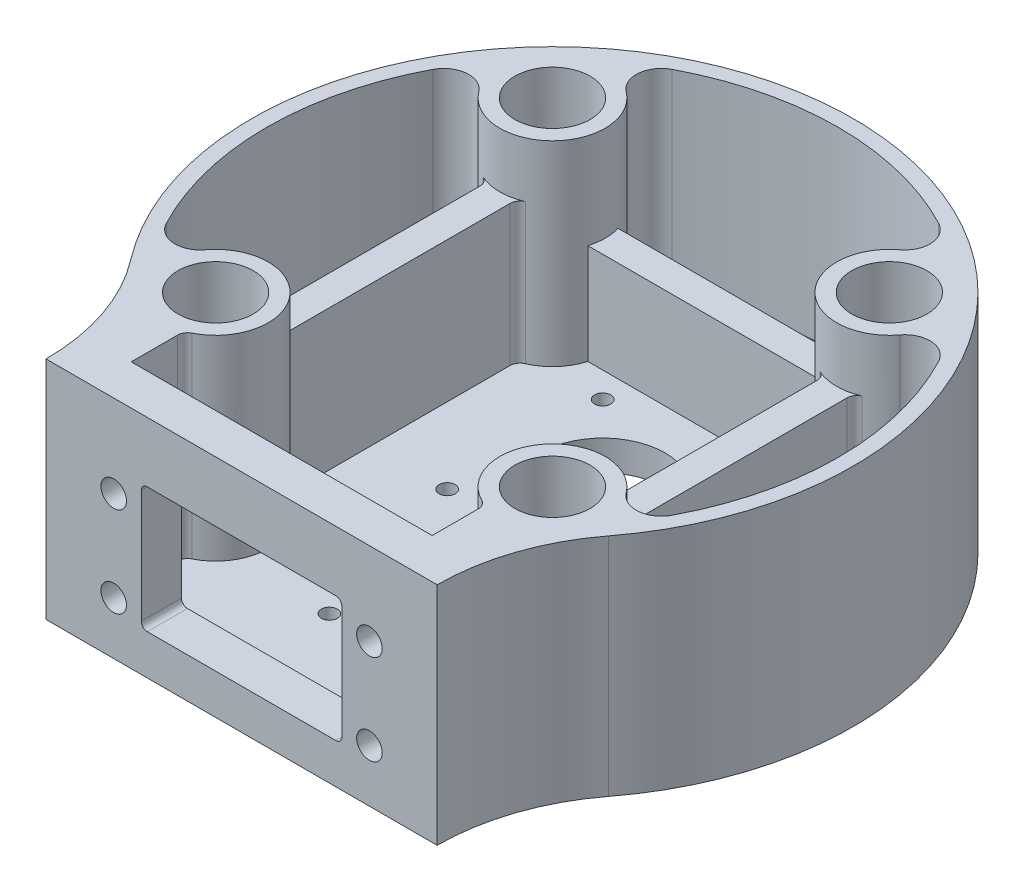
from build123d import *

# Parameters (mm, degrees)
SKETCH1_R           = 7.5
BOSS_EXTRUDE1_DEPTH = 45
BOSS_EXTRUDE2_DEPTH = 6
SKETCH3_R           = 5.25
SKETCH3_R_2         = 4.25
SKETCH3_R_3         = 1.6
CUT_EXTRUDE1_DEPTH  = 7
FILLET1_R           = 5
SKETCH4_R           = 5.1
CUT_EXTRUDE2_DEPTH  = 2
SKETCH5_R           = 12.5
SKETCH5_R_2         = 1.6
CUT_EXTRUDE3_DEPTH  = 46.0000001
CUT_EXTRUDE4_REACH  = 124
SKETCH6_W           = 40
SKETCH6_H           = 25
CUT_EXTRUDE5_REACH  = 124
SKETCH7_R           = 2.55
BOSS_EXTRUDE3_DEPTH = 28
FILLET2_R           = 2
BOSS_EXTRUDE4_DEPTH = 20
FILLET3_R           = 1.2


with BuildPart() as part:
    # Sketch1 → Boss-Extrude1 (new body)
    with BuildSketch(Plane(origin=(0, 0, 0), x_dir=(1, 0, 0), z_dir=(0, 1, 0))):
        with BuildLine():
            ThreePointArc((-47.647058368, -36.465844689), (-41.21916632, -48.520286728), (-39, -62))
            Line((-39, -62), (39, -62))
            ThreePointArc((39, -62), (41.21916632, -48.520286728), (47.647058368, -36.465844689))
            ThreePointArc((47.647058368, -36.465844689), (0, 60), (-47.647058368, -36.465844689))
        make_face()
        with Locations((-33.587572106, -33.587572106)):
            Circle(SKETCH1_R, mode=Mode.SUBTRACT)
        with Locations((33.587572106, -33.587572106)):
            Circle(SKETCH1_R, mode=Mode.SUBTRACT)
        with Locations((-33.587572106, 33.587572106)):
            Circle(SKETCH1_R, mode=Mode.SUBTRACT)
        with BuildLine():
            Line((30, -54), (-30, -54))
            Line((-30, -54), (-30, -48.466483264))
            ThreePointArc((-30, -48.466483264), (-33.435692219, -46.163345696), (-36.695320422, -43.617123463))
            ThreePointArc((-36.695320422, -43.617123463), (-33.334442408, -44.084520489), (-30, -43.455668497))
            ThreePointArc((-30, -43.455668497), (-28.91848754, -24.182804735), (-43.617123463, -36.695320422))
            ThreePointArc((-43.617123463, -36.695320422), (-57, 0), (-43.617123463, 36.695320422))
            ThreePointArc((-43.617123463, 36.695320422), (-26.162950904, 26.162950904), (-36.695320422, 43.617123463))
            ThreePointArc((-36.695320422, 43.617123463), (0, 57), (36.695320422, 43.617123463))
            ThreePointArc((36.695320422, 43.617123463), (26.162950904, 26.162950904), (43.617123463, 36.695320422))
            ThreePointArc((43.617123463, 36.695320422), (57, 0), (43.617123463, -36.695320422))
            ThreePointArc((43.617123463, -36.695320422), (28.91848754, -24.182804735), (30, -43.455668497))
            ThreePointArc((30, -43.455668497), (33.334442408, -44.084520489), (36.695320422, -43.617123463))
            ThreePointArc((36.695320422, -43.617123463), (33.435692219, -46.163345696), (30, -48.466483264))
            Line((30, -48.466483264), (30, -54))
        make_face(mode=Mode.SUBTRACT)
        with Locations((33.587572106, 33.587572106)):
            Circle(SKETCH1_R, mode=Mode.SUBTRACT)
        with BuildLine():
            Line((30, -43.455668497), (30, -48.466483264))
            ThreePointArc((30, -48.466483264), (33.435692219, -46.163345696), (36.695320422, -43.617123463))
            ThreePointArc((36.695320422, -43.617123463), (33.334442408, -44.084520489), (30, -43.455668497))
        make_face()
        with BuildLine():
            ThreePointArc((-36.695320422, -43.617123463), (-33.435692219, -46.163345696), (-30, -48.466483264))
            Line((-30, -48.466483264), (-30, -43.455668497))
            ThreePointArc((-30, -43.455668497), (-33.334442408, -44.084520489), (-36.695320422, -43.617123463))
        make_face()
    extrude(amount=BOSS_EXTRUDE1_DEPTH)

    # Sketch2 → Boss-Extrude2 (add)
    with BuildSketch(Plane.XZ):
        with BuildLine():
            Line((39, 62), (-39, 62))
            ThreePointArc((-39, 62), (-41.21916632, 48.520286728), (-47.647058368, 36.465844689))
            ThreePointArc((-47.647058368, 36.465844689), (0, -60), (47.647058368, 36.465844689))
            ThreePointArc((47.647058368, 36.465844689), (41.21916632, 48.520286728), (39, 62))
        make_face()
    extrude(amount=-BOSS_EXTRUDE2_DEPTH)

    # Sketch3 → Cut-Extrude1 (cut, through all)
    with BuildSketch(Plane(origin=(0, 6, 0), x_dir=(1, 0, 0), z_dir=(0, 1, 0))):
        with Locations((-33.587572106, 33.587572106)):
            Circle(SKETCH3_R)
        with Locations((33.587572106, 33.587572106)):
            Circle(SKETCH3_R)
        with Locations((33.587572106, -33.587572106)):
            Circle(SKETCH3_R)
        with Locations((-33.587572106, -33.587572106)):
            Circle(SKETCH3_R)
        with Locations((0, -33)):
            Circle(SKETCH3_R_2)
        with Locations((-5.75, -27.25)):
            Circle(SKETCH3_R_3)
        with Locations((5.75, -27.25)):
            Circle(SKETCH3_R_3)
        with Locations((5.75, -38.75)):
            Circle(SKETCH3_R_3)
        with Locations((-5.75, -38.75)):
            Circle(SKETCH3_R_3)
    extrude(amount=-CUT_EXTRUDE1_DEPTH, mode=Mode.SUBTRACT)

    # Fillet1
    fillet1_edges = [part.edges().sort_by_distance(p)[0] for p in [
        (43.617123463, 25.5, 36.695320422),
        (43.617123463, 25.5, -36.695320422),
        (36.695320422, 25.5, -43.617123463),
        (-36.695320422, 25.5, -43.617123463),
        (-43.617123463, 25.5, -36.695320422),
        (-43.617123463, 25.5, 36.695320422),
    ]]
    fillet(fillet1_edges, radius=FILLET1_R)

    # Sketch4 → Cut-Extrude2 (cut)
    with BuildSketch(Plane(origin=(0, 6, 0), x_dir=(1, 0, 0), z_dir=(0, 1, 0))):
        with Locations((0, -33)):
            Circle(SKETCH4_R)
    extrude(amount=-CUT_EXTRUDE2_DEPTH, mode=Mode.SUBTRACT)

    # Sketch5 → Cut-Extrude3 (cut, through all)
    with BuildSketch(Plane.XZ):
        with Locations((0, -10)):
            Circle(SKETCH5_R)
        with Locations((15.5, 5.5)):
            Circle(SKETCH5_R_2)
        with Locations((-15.5, 5.5)):
            Circle(SKETCH5_R_2)
        with Locations((-15.5, -25.5)):
            Circle(SKETCH5_R_2)
        with Locations((15.5, -25.5)):
            Circle(SKETCH5_R_2)
    extrude(amount=-CUT_EXTRUDE3_DEPTH, mode=Mode.SUBTRACT)

    # Sketch6 → Cut-Extrude4 (cut, up to next)
    with BuildSketch(Plane.XY.offset(62), mode=Mode.PRIVATE) as cut_extrude4_sk1:
        with Locations((0, 20.5)):
            Rectangle(SKETCH6_W, SKETCH6_H)
    cut_extrude4_tool1 = extrude(cut_extrude4_sk1.sketch, amount=-CUT_EXTRUDE4_REACH, mode=Mode.PRIVATE) & part.part
    add(cut_extrude4_tool1.solids().sort_by_distance((0, 20.5, 62))[0], mode=Mode.SUBTRACT)

    # Sketch7 → Cut-Extrude5 (cut, up to next)
    with BuildSketch(Plane.XY.offset(62), mode=Mode.PRIVATE) as cut_extrude5_sk1:
        with Locations((-25.5, 10.5)):
            Circle(SKETCH7_R)
    cut_extrude5_tool1 = extrude(cut_extrude5_sk1.sketch, amount=-CUT_EXTRUDE5_REACH, mode=Mode.PRIVATE) & part.part
    add(cut_extrude5_tool1.solids().sort_by_distance((-25.5, 10.5, 62))[0], mode=Mode.SUBTRACT)
    # Sketch7 → Cut-Extrude5 (cut, up to next)
    with BuildSketch(Plane.XY.offset(62), mode=Mode.PRIVATE) as cut_extrude5_sk2:
        with Locations((25.5, 10.5)):
            Circle(SKETCH7_R)
    cut_extrude5_tool2 = extrude(cut_extrude5_sk2.sketch, amount=-CUT_EXTRUDE5_REACH, mode=Mode.PRIVATE) & part.part
    add(cut_extrude5_tool2.solids().sort_by_distance((25.5, 10.5, 62))[0], mode=Mode.SUBTRACT)
    # Sketch7 → Cut-Extrude5 (cut, up to next)
    with BuildSketch(Plane.XY.offset(62), mode=Mode.PRIVATE) as cut_extrude5_sk3:
        with Locations((25.5, 28.5)):
            Circle(SKETCH7_R)
    cut_extrude5_tool3 = extrude(cut_extrude5_sk3.sketch, amount=-CUT_EXTRUDE5_REACH, mode=Mode.PRIVATE) & part.part
    add(cut_extrude5_tool3.solids().sort_by_distance((25.5, 28.5, 62))[0], mode=Mode.SUBTRACT)
    # Sketch7 → Cut-Extrude5 (cut, up to next)
    with BuildSketch(Plane.XY.offset(62), mode=Mode.PRIVATE) as cut_extrude5_sk4:
        with Locations((-25.5, 28.5)):
            Circle(SKETCH7_R)
    cut_extrude5_tool4 = extrude(cut_extrude5_sk4.sketch, amount=-CUT_EXTRUDE5_REACH, mode=Mode.PRIVATE) & part.part
    add(cut_extrude5_tool4.solids().sort_by_distance((-25.5, 28.5, 62))[0], mode=Mode.SUBTRACT)

    # Sketch8 → Boss-Extrude3 (add)
    with BuildSketch(Plane(origin=(0, 6, 0), x_dir=(1, 0, 0), z_dir=(0, 1, 0))):
        with BuildLine():
            Line((-36.587572106, 23.525266208), (-36.587572106, -23.525266208))
            ThreePointArc((-36.587572106, -23.525266208), (-33.587572106, -23.087572106), (-30.587572106, -23.525266208))
            Line((-30.587572106, -23.525266208), (-30.587572106, 23.525266208))
            ThreePointArc((-30.587572106, 23.525266208), (-33.587572106, 23.087572106), (-36.587572106, 23.525266208))
        make_face()
        with BuildLine():
            Line((30.587572106, 23.525266208), (30.587572106, -23.525266208))
            ThreePointArc((30.587572106, -23.525266208), (33.587572106, -23.087572106), (36.587572106, -23.525266208))
            Line((36.587572106, -23.525266208), (36.587572106, 23.525266208))
            ThreePointArc((36.587572106, 23.525266208), (33.587572106, 23.087572106), (30.587572106, 23.525266208))
        make_face()
    extrude(amount=BOSS_EXTRUDE3_DEPTH)

    # Fillet2
    fillet2_edges = [part.edges().sort_by_distance(p)[0] for p in [
        (-30.587572106, 20, -23.525266208),
        (-36.587572106, 20, -23.525266208),
        (-36.587572106, 20, 23.525266208),
        (-30.587572106, 20, 23.525266208),
        (30.587572106, 20, 23.525266208),
        (36.587572106, 20, 23.525266208),
        (36.587572106, 20, -23.525266208),
        (30.587572106, 20, -23.525266208),
        (30, 25.5, 43.455668497),
        (-30, 25.5, 43.455668497),
    ]]
    fillet(fillet2_edges, radius=FILLET2_R)

    # Sketch9 → Boss-Extrude4 (add)
    with BuildSketch(Plane(origin=(0, 6, 0), x_dir=(1, 0, 0), z_dir=(0, 1, 0))):
        with BuildLine():
            Line((-23.525266208, 30.587572106), (23.525266208, 30.587572106))
            ThreePointArc((23.525266208, 30.587572106), (23.087572106, 33.587572106), (23.525266208, 36.587572106))
            Line((23.525266208, 36.587572106), (-23.525266208, 36.587572106))
            ThreePointArc((-23.525266208, 36.587572106), (-23.087572106, 33.587572106), (-23.525266208, 30.587572106))
        make_face()
    extrude(amount=BOSS_EXTRUDE4_DEPTH)

    # Fillet3
    fillet3_edges = [part.edges().sort_by_distance(p)[0] for p in [
        (20, 33, 58),
        (20, 8, 58),
        (-20, 8, 58),
        (-20, 33, 58),
    ]]
    fillet(fillet3_edges, radius=FILLET3_R)


solid = part.part
